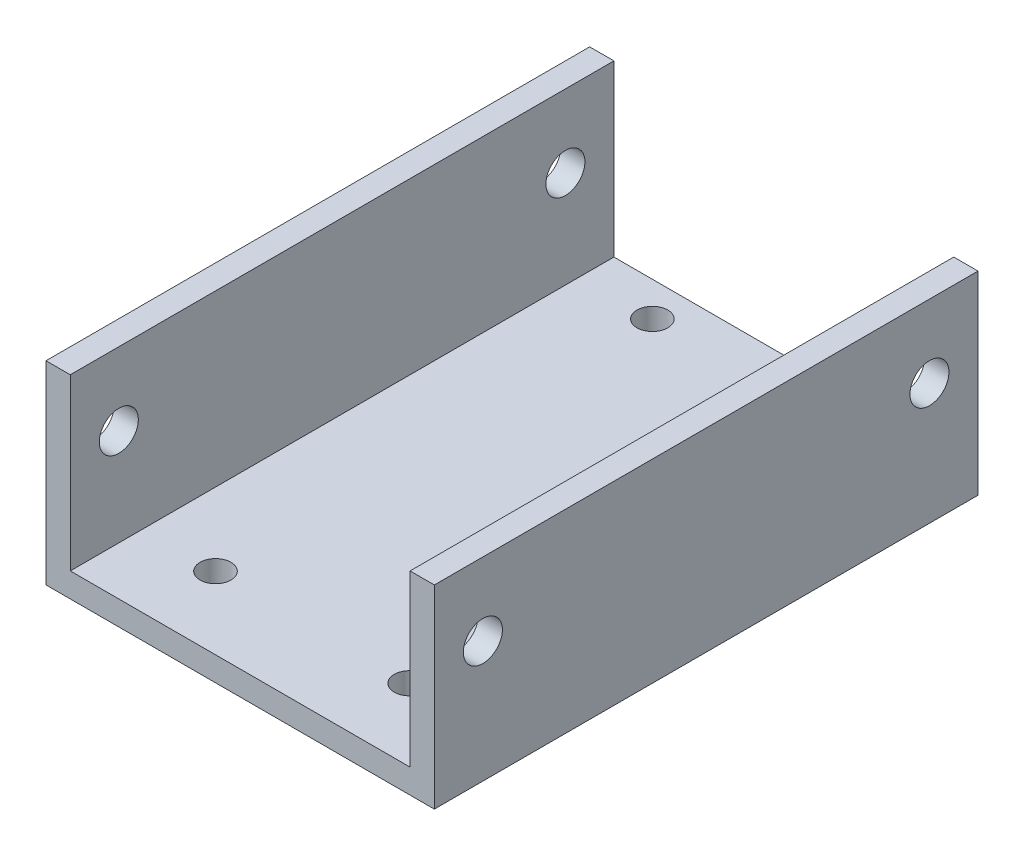
from build123d import *

# Parameters (mm, degrees)
BOSS_EXTRUDE1_DEPTH = 71.12
CUT_EXTRUDE1_REACH  = 5.175
SKETCH2_R           = 2.0193
SKETCH3_R           = 2.5527
CUT_EXTRUDE2_DEPTH  = 51.8


with BuildPart() as part:
    # Sketch1 → Boss-Extrude1 (new body)
    with BuildSketch(Plane.XY):
        Polygon((47.625, 3.175), (47.625, 25.4), (50.8, 25.4), (50.8, 0), (0, 0), (0, 25.4), (3.175, 25.4), (3.175, 3.175), align=None)
    extrude(amount=BOSS_EXTRUDE1_DEPTH)

    # Sketch2 → Cut-Extrude1 (cut, up to next)
    with BuildSketch(Plane(origin=(0, 3.175, 0), x_dir=(1, 0, 0), z_dir=(0, 1, 0)), mode=Mode.PRIVATE) as cut_extrude1_sk1:
        with Locations((38.1, -4.4975)):
            Circle(SKETCH2_R)
    cut_extrude1_tool1 = extrude(cut_extrude1_sk1.sketch, amount=-CUT_EXTRUDE1_REACH, mode=Mode.PRIVATE) & part.part
    add(cut_extrude1_tool1.solids().sort_by_distance((38.1, 3.175, 4.4975))[0], mode=Mode.SUBTRACT)
    # Sketch2 → Cut-Extrude1 (cut, up to next)
    with BuildSketch(Plane(origin=(0, 3.175, 0), x_dir=(1, 0, 0), z_dir=(0, 1, 0)), mode=Mode.PRIVATE) as cut_extrude1_sk2:
        with Locations((38.1, -61.6475)):
            Circle(SKETCH2_R)
    cut_extrude1_tool2 = extrude(cut_extrude1_sk2.sketch, amount=-CUT_EXTRUDE1_REACH, mode=Mode.PRIVATE) & part.part
    add(cut_extrude1_tool2.solids().sort_by_distance((38.1, 3.175, 61.6475))[0], mode=Mode.SUBTRACT)
    # Sketch2 → Cut-Extrude1 (cut, up to next)
    with BuildSketch(Plane(origin=(0, 3.175, 0), x_dir=(1, 0, 0), z_dir=(0, 1, 0)), mode=Mode.PRIVATE) as cut_extrude1_sk3:
        with Locations((12.7, -4.4975)):
            Circle(SKETCH2_R)
    cut_extrude1_tool3 = extrude(cut_extrude1_sk3.sketch, amount=-CUT_EXTRUDE1_REACH, mode=Mode.PRIVATE) & part.part
    add(cut_extrude1_tool3.solids().sort_by_distance((12.7, 3.175, 4.4975))[0], mode=Mode.SUBTRACT)
    # Sketch2 → Cut-Extrude1 (cut, up to next)
    with BuildSketch(Plane(origin=(0, 3.175, 0), x_dir=(1, 0, 0), z_dir=(0, 1, 0)), mode=Mode.PRIVATE) as cut_extrude1_sk4:
        with Locations((12.7, -61.6475)):
            Circle(SKETCH2_R)
    cut_extrude1_tool4 = extrude(cut_extrude1_sk4.sketch, amount=-CUT_EXTRUDE1_REACH, mode=Mode.PRIVATE) & part.part
    add(cut_extrude1_tool4.solids().sort_by_distance((12.7, 3.175, 61.6475))[0], mode=Mode.SUBTRACT)

    # Sketch3 → Cut-Extrude2 (cut, through all)
    with BuildSketch(Plane(origin=(50.8, 0, 0), x_dir=(0, 0, -1), z_dir=(1, 0, 0))):
        with Locations((-6.35, 15.875)):
            Circle(SKETCH3_R)
        with Locations((-64.77, 15.875)):
            Circle(SKETCH3_R)
    extrude(amount=-CUT_EXTRUDE2_DEPTH, mode=Mode.SUBTRACT)


solid = part.part
